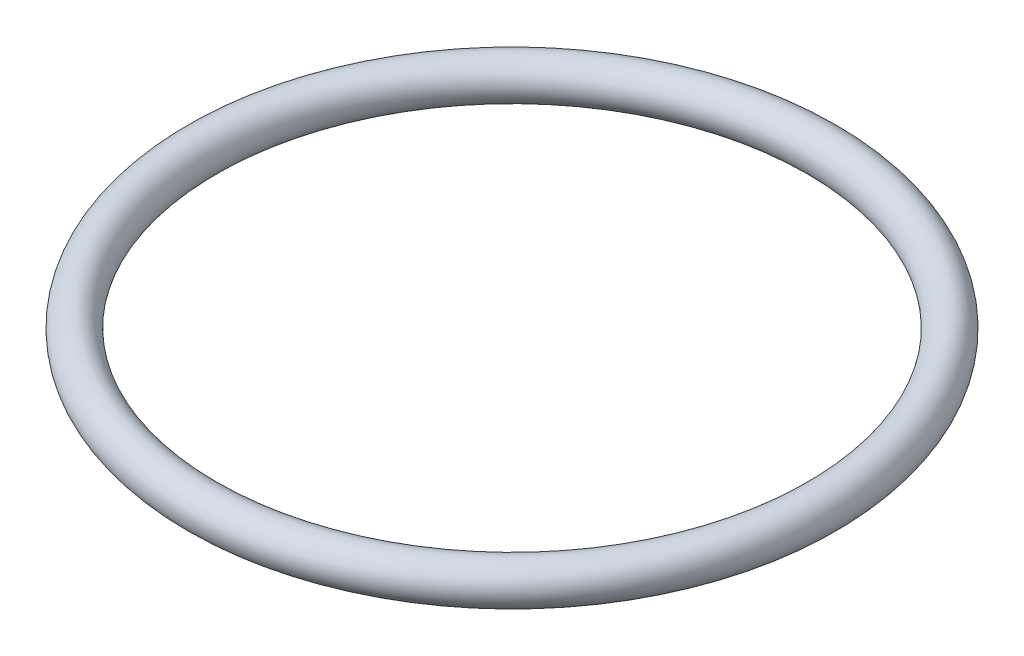
from build123d import *

# Parameters (mm, degrees)
SKETCH_1_R = 7


with BuildPart() as part:
    # 草图1 → 旋转1 (revolve)
    with BuildSketch(Plane.XY):
        with Locations((108, 0)):
            Circle(SKETCH_1_R)
    revolve(axis=Axis((0, 0, 0), (0, 1, 0)))


solid = part.part
